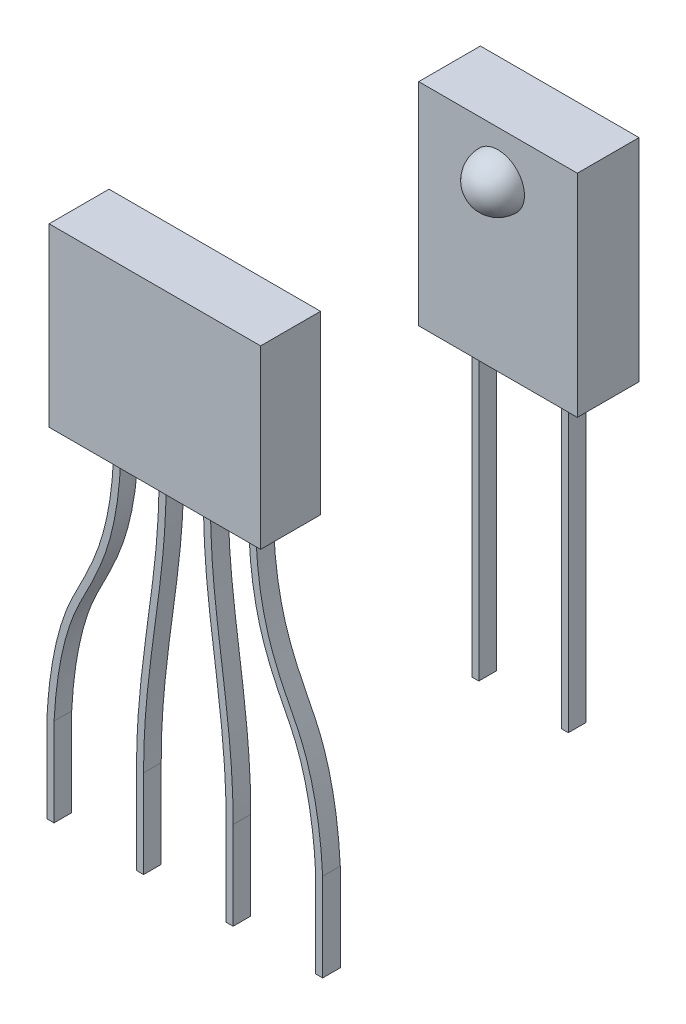
from build123d import *

# Parameters (mm, degrees)
SKETCH1_W                = 3.18
SKETCH1_H                = 8.32
SKETCH1_W_2              = 8.26
SKETCH1_H_2              = 3.18
SKETCH1_H_3              = 8.26
SKETCH1_H_4              = 5.72
SKETCH1_W_3              = 3.94
SKETCH1_H_5              = 12.7
BOSS_EXTRUDE2_DEPTH      = 1.6
BOSS_EXTRUDE3_START      = 8
BOSS_EXTRUDE3_DEPTH      = 5
BOSS_EXTRUDE4_START      = -1.1
BOSS_EXTRUDE4_DEPTH      = 0.25
BOSS_EXTRUDE4_DEPTH_BACK = 0.25
CHAMFER1_SIZE            = 0.5
BOSS_EXTRUDE5_START      = 6
SKETCH5_W                = 4.5
SKETCH5_H                = 1.75
BOSS_EXTRUDE5_DEPTH      = 6
BOSS_EXTRUDE6_START      = -0.875
SKETCH7_W                = 0.2
SKETCH7_H                = 6
BOSS_EXTRUDE6_DEPTH      = 0.25
BOSS_EXTRUDE6_DEPTH_BACK = 0.25
SKETCH8_R                = 0.635
CUT_EXTRUDE1_DEPTH       = 2.6
SKETCH9_W                = 71.682790583
SKETCH9_H                = 73.419144216
CUT_EXTRUDE2_DEPTH       = 1.6
SKETCH10_W               = 0.200265949
SKETCH10_H               = 0.5
SKETCH10_W_2             = 0.200003992
SKETCH10_W_3             = 0.2
BOSS_EXTRUDE7_DEPTH      = 2.5


with BuildPart() as part:
    # Sketch1 → Boss-Extrude2 (new body)
    with BuildSketch(Plane(origin=(0, 0, 0), x_dir=(1, 0, 0), z_dir=(0, 1, 0))):
        Polygon((-23.815, 0), (-23.815, 29.84), (24.115, 29.84), (24.115, 0), (24.115, -29.84), (-23.815, -29.84), align=None)
        with Locations((-20.955, 15.53)):
            Rectangle(SKETCH1_W, SKETCH1_H, mode=Mode.SUBTRACT)
        with Locations((-4.445, 7.93)):
            Rectangle(SKETCH1_W_2, SKETCH1_H_2, mode=Mode.SUBTRACT)
        with Locations((-20.955, -0.94)):
            Rectangle(SKETCH1_W, SKETCH1_H_3, mode=Mode.SUBTRACT)
        with Locations((21.005, 25.71)):
            Rectangle(SKETCH1_W, SKETCH1_H_4, mode=Mode.SUBTRACT)
        with Locations((20.305, -15.55)):
            Rectangle(SKETCH1_W, SKETCH1_H_3, mode=Mode.SUBTRACT)
        with Locations((14.845, -9.58)):
            Rectangle(SKETCH1_W_3, SKETCH1_H_5, mode=Mode.SUBTRACT)
    extrude(amount=BOSS_EXTRUDE2_DEPTH)



with BuildPart() as body_2:
    # Sketch3 → Boss-Extrude3 (new body)
    with BuildSketch(Plane(origin=(0, 1.6, 0), x_dir=(1, 0, 0), z_dir=(0, 1, 0)).offset(BOSS_EXTRUDE3_START)):
        Polygon((0.315, -7.78), (-2.685, -7.78), (-2.685, -9.98), (0.315, -9.98), (3.315, -9.98), (3.315, -7.78), align=None)
    extrude(amount=BOSS_EXTRUDE3_DEPTH)


with BuildPart() as part_1:
    add(part.part)

    add(body_2.part)  # Boss-Extrude4 merges body 2
    # Sketch4 → Boss-Extrude4 (add, two sides)
    with BuildSketch(Plane.XY.offset(9.98).offset(BOSS_EXTRUDE4_START)) as boss_extrude4_sk:
        with BuildLine():
            Line((-1.690000547, 9.6), (-1.489999461, 9.6))
            add(Edge.make_bspline(
                [(-1.489999461, 9.6), (-1.490724676, 9.378615191), (-1.501150351, 8.921966702), (-1.557643402, 8.121923712), (-1.697410233, 7.229711912), (-1.97391224, 6.293277185), (-2.377283852, 5.415108244), (-2.844851076, 4.550624944), (-3.233739916, 3.293659471), (-3.359982321, 2.27142251), (-3.394866088, 1.6)],
                knots=[-2.4969e-05, -2.4969e-05, -2.4969e-05, -2.4969e-05, 0.05029142, 0.100582839, 0.201165679, 0.301748518, 0.402331357, 0.502914197, 0.603497036, 0.80414952, 0.80414952, 0.80414952, 0.80414952], degree=3))
            Line((-3.394866088, 1.6), (-3.595132037, 1.6))
            add(Edge.make_bspline(
                [(-1.690000547, 9.6), (-1.69072463, 9.38164845), (-1.701031258, 8.930534953), (-1.756658157, 8.144235526), (-1.893064323, 7.273307969), (-2.162944464, 6.361554733), (-2.550643297, 5.515600408), (-3.030540836, 4.627219412), (-3.432934775, 3.326482293), (-3.559913653, 2.287505886), (-3.595132037, 1.6)],
                knots=[2.5291e-05, 2.5291e-05, 2.5291e-05, 2.5291e-05, 0.05029142, 0.100582839, 0.201165679, 0.301748518, 0.402331357, 0.502914197, 0.603497036, 0.805166415, 0.805166415, 0.805166415, 0.805166415], degree=3))
        make_face()
        with BuildLine():
            Line((-0.420030875, 9.6), (-0.219969453, 9.6))
            add(Edge.make_bspline(
                [(-0.219969453, 9.6), (-0.215286197, 9.410037733), (-0.211453119, 9.021656245), (-0.225743152, 8.30492942), (-0.299753538, 7.127767003), (-0.503670741, 5.597842901), (-0.770994323, 3.658720552), (-0.859324782, 2.280063776), (-0.85499799, 1.6)],
                knots=[0.000218879, 0.000218879, 0.000218879, 0.000218879, 0.050557538, 0.101115077, 0.202230153, 0.404460306, 0.606690459, 0.808983257, 0.808983257, 0.808983257, 0.808983257], degree=3))
            Line((-0.85499799, 1.6), (-1.055001982, 1.6))
            add(Edge.make_bspline(
                [(-0.420030875, 9.6), (-0.415306869, 9.410414309), (-0.411448243, 9.024159618), (-0.425621065, 8.313593273), (-0.498810074, 7.148902433), (-0.701395153, 5.627430708), (-0.96986031, 3.682389129), (-1.05931075, 2.286737109), (-1.055001982, 1.6)],
                knots=[-0.000221191, -0.000221191, -0.000221191, -0.000221191, 0.050557538, 0.101115077, 0.202230153, 0.404460306, 0.606690459, 0.808858614, 0.808858614, 0.808858614, 0.808858614], degree=3))
        make_face()
        with BuildLine():
            Line((0.849969454, 9.6), (1.050030874, 9.6))
            add(Edge.make_bspline(
                [(1.050030874, 9.6), (1.045306869, 9.410414309), (1.041448243, 9.024159618), (1.055621064, 8.313593273), (1.128810074, 7.148902433), (1.331395152, 5.627430708), (1.599860309, 3.682389129), (1.689310749, 2.286737109), (1.685001982, 1.6)],
                knots=[-0.000221191, -0.000221191, -0.000221191, -0.000221191, 0.050557538, 0.101115077, 0.202230153, 0.404460306, 0.606690459, 0.808858614, 0.808858614, 0.808858614, 0.808858614], degree=3))
            Line((1.685001982, 1.6), (1.48499799, 1.6))
            add(Edge.make_bspline(
                [(0.849969454, 9.6), (0.845286198, 9.410037733), (0.841453119, 9.021656245), (0.855743152, 8.30492942), (0.929753538, 7.127767003), (1.133670741, 5.597842901), (1.400994323, 3.658720552), (1.489324782, 2.280063776), (1.48499799, 1.6)],
                knots=[0.000218879, 0.000218879, 0.000218879, 0.000218879, 0.050557538, 0.101115077, 0.202230153, 0.404460306, 0.606690459, 0.808983257, 0.808983257, 0.808983257, 0.808983257], degree=3))
        make_face()
        with BuildLine():
            Line((2.11999946, 9.6), (2.320000547, 9.6))
            add(Edge.make_bspline(
                [(2.320000547, 9.6), (2.320724629, 9.38164845), (2.331031257, 8.930534953), (2.386658156, 8.144235526), (2.523064322, 7.273307969), (2.792944463, 6.361554733), (3.180643297, 5.515600408), (3.660540836, 4.627219412), (4.062934774, 3.326482293), (4.189913652, 2.287505886), (4.225132036, 1.6)],
                knots=[2.5291e-05, 2.5291e-05, 2.5291e-05, 2.5291e-05, 0.05029142, 0.100582839, 0.201165679, 0.301748518, 0.402331357, 0.502914197, 0.603497036, 0.805166415, 0.805166415, 0.805166415, 0.805166415], degree=3))
            Line((4.225132036, 1.6), (4.024866087, 1.6))
            add(Edge.make_bspline(
                [(2.11999946, 9.6), (2.120724676, 9.378615191), (2.13115035, 8.921966702), (2.187643402, 8.121923712), (2.327410232, 7.229711912), (2.60391224, 6.293277185), (3.007283851, 5.415108244), (3.474851076, 4.550624944), (3.863739916, 3.293659471), (3.98998232, 2.27142251), (4.024866087, 1.6)],
                knots=[-2.4969e-05, -2.4969e-05, -2.4969e-05, -2.4969e-05, 0.05029142, 0.100582839, 0.201165679, 0.301748518, 0.402331357, 0.502914197, 0.603497036, 0.80414952, 0.80414952, 0.80414952, 0.80414952], degree=3))
        make_face()
    extrude(amount=BOSS_EXTRUDE4_DEPTH)
    extrude(boss_extrude4_sk.sketch, amount=-BOSS_EXTRUDE4_DEPTH_BACK)

    # Chamfer1
    chamfer1_edges = [part_1.edges().sort_by_distance(p)[0] for p in [
        (0.315, 9.6, 7.78),
        (3.315, 12.1, 7.78),
        (-2.685, 12.1, 7.78),
        (0.315, 14.6, 7.78),
    ]]
    chamfer(chamfer1_edges, length=CHAMFER1_SIZE)



with BuildPart() as body_2_2:
    # Sketch5 → Boss-Extrude5 (new body)
    with BuildSketch(Plane(origin=(0, 1.6, 0), x_dir=(1, 0, 0), z_dir=(0, 1, 0)).offset(BOSS_EXTRUDE5_START)):
        with Locations((0.315, 0.63)):
            Rectangle(SKETCH5_W, SKETCH5_H)
    extrude(amount=BOSS_EXTRUDE5_DEPTH)

    # Sketch6 → Revolve1 (revolve)
    with BuildSketch(Plane.XY.offset(0.245)):
        with BuildLine():
            Line((0.315, 13.05), (0.315, 12.3))
            Line((0.315, 12.3), (0.315, 11.55))
            ThreePointArc((0.315, 11.55), (1.065, 12.3), (0.315, 13.05))
        make_face()
    revolve(axis=Axis((0.315, 13.05, 0.245), (0, -1, 0)))


with BuildPart() as part_2:
    add(part_1.part)

    add(body_2_2.part)  # Boss-Extrude6 merges body 2 2
    # Sketch7 → Boss-Extrude6 (add, two sides)
    with BuildSketch(Plane(origin=(0, 0, -1.505), x_dir=(-1, 0, 0), z_dir=(0, 0, -1)).offset(BOSS_EXTRUDE6_START)) as boss_extrude6_sk:
        with Locations((-1.585, 4.6)):
            Rectangle(SKETCH7_W, SKETCH7_H)
        with Locations((0.955, 4.6)):
            Rectangle(SKETCH7_W, SKETCH7_H)
    extrude(amount=BOSS_EXTRUDE6_DEPTH)
    extrude(boss_extrude6_sk.sketch, amount=-BOSS_EXTRUDE6_DEPTH_BACK)

    # Sketch8 → Cut-Extrude1 (cut, through all)
    with BuildSketch(Plane(origin=(0, 1.6, 0), x_dir=(1, 0, 0), z_dir=(0, 1, 0))):
        with Locations((-0.955, 4.44)):
            Circle(SKETCH8_R)
        with Locations((1.585, 4.44)):
            Circle(SKETCH8_R)
        with Locations((4.125, 4.44)):
            Circle(SKETCH8_R)
        with Locations((-3.495, 4.44)):
            Circle(SKETCH8_R)
        with Locations((-7.815, 4.016666667)):
            Circle(SKETCH8_R)
        with Locations((-14.365, 4.016666667)):
            Circle(SKETCH8_R)
        with Locations((-14.365, -0.503333333)):
            Circle(SKETCH8_R)
        with Locations((-7.815, -0.503333333)):
            Circle(SKETCH8_R)
        with Locations((14.995, -0.503333333)):
            Circle(SKETCH8_R)
        with Locations((8.445, -0.503333333)):
            Circle(SKETCH8_R)
        with Locations((14.995, 4.016666667)):
            Circle(SKETCH8_R)
        with Locations((8.445, 4.016666667)):
            Circle(SKETCH8_R)
    extrude(amount=-CUT_EXTRUDE1_DEPTH, mode=Mode.SUBTRACT)

    # Sketch9 → Cut-Extrude2 (cut)
    with BuildSketch(Plane.XZ):
        with Locations((0.802366539, 0.541931826)):
            Rectangle(SKETCH9_W, SKETCH9_H)
    extrude(amount=-CUT_EXTRUDE2_DEPTH, mode=Mode.SUBTRACT)

    # Sketch10 → Boss-Extrude7 (add)
    with BuildSketch(Plane.XZ.offset(-1.6)):
        with Locations((-3.494999063, 8.88)):
            Rectangle(SKETCH10_W, SKETCH10_H)
        with Locations((-0.954999986, 8.88)):
            Rectangle(SKETCH10_W_2, SKETCH10_H)
        with Locations((1.584999986, 8.88)):
            Rectangle(SKETCH10_W_2, SKETCH10_H)
        with Locations((4.124999062, 8.88)):
            Rectangle(SKETCH10_W, SKETCH10_H)
        with Locations((-0.955, -0.63)):
            Rectangle(SKETCH10_W_3, SKETCH10_H)
        with Locations((1.585, -0.63)):
            Rectangle(SKETCH10_W_3, SKETCH10_H)
    extrude(amount=BOSS_EXTRUDE7_DEPTH)


solid = part_2.part
